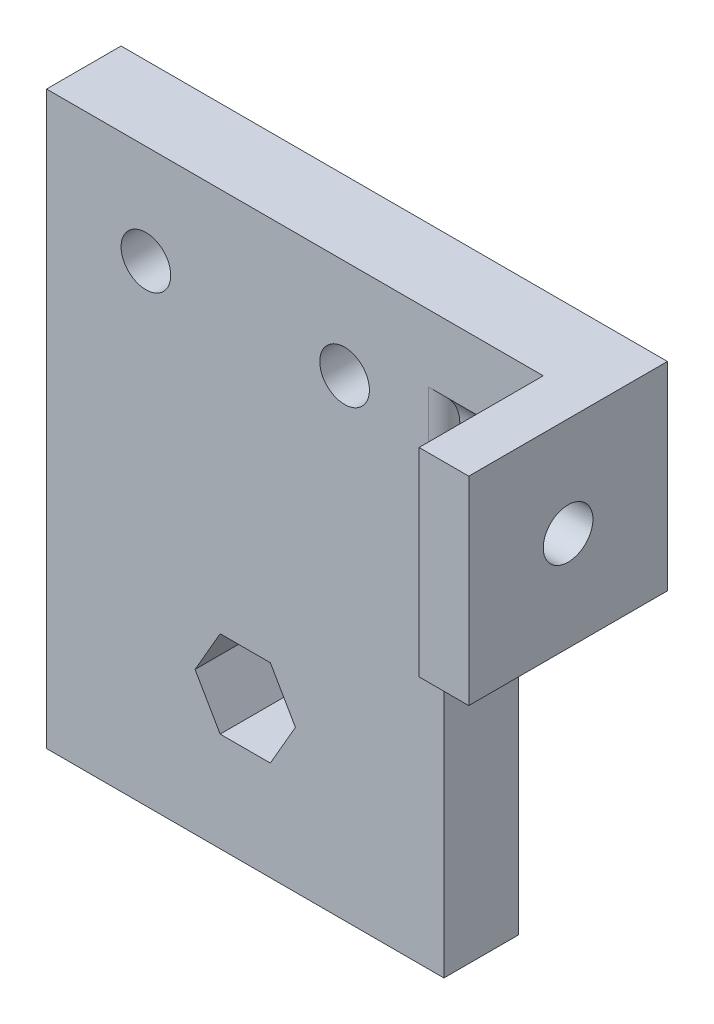
from build123d import *

# Parameters (mm, degrees)
SKETCH2_R      = 3.175
EXTRUDE1_DEPTH = 9.525
EXTRUDE2_START = 12.7
SKETCH3_W      = 25.4
SKETCH3_H      = 25.4
SKETCH3_R      = 3.175
EXTRUDE2_DEPTH = 6.35
SKETCH4_R      = 5.207
EXTRUDE3_DEPTH = 12.7
FILLET4_R      = 2


with BuildPart() as part:
    # Sketch2 → Extrude1 (new body)
    with BuildSketch(Plane.XY):
        Polygon((0, 0), (50.8, 0), (50.8, 47.625), (63.5, 47.625), (63.5, 73.025), (50.8, 73.025), (0, 73.025), align=None)
        with Locations((12.7, 60.325)):
            Circle(SKETCH2_R, mode=Mode.SUBTRACT)
        with Locations((38.1, 60.325)):
            Circle(SKETCH2_R, mode=Mode.SUBTRACT)
        Polygon((31.815804866, 18.25625), (28.607902433, 23.8125), (22.192097567, 23.8125), (18.984195134, 18.25625), (22.192097567, 12.7), (28.607902433, 12.7), align=None, mode=Mode.SUBTRACT)
    extrude(amount=EXTRUDE1_DEPTH)

    # Sketch3 → Extrude2 (add)
    with BuildSketch(Plane(origin=(50.8, 0, 0), x_dir=(0, 0, -1), z_dir=(1, 0, 0)).offset(EXTRUDE2_START)):
        with Locations((-12.7, 60.325)):
            Rectangle(SKETCH3_W, SKETCH3_H)
        with Locations((-12.7, 60.325)):
            Circle(SKETCH3_R, mode=Mode.SUBTRACT)
    extrude(amount=EXTRUDE2_DEPTH)

    # Sketch4 → Extrude3 (cut)
    with BuildSketch(Plane.ZY.offset(-63.5)):
        with Locations((12.7, 60.325)):
            Circle(SKETCH4_R)
    extrude(amount=EXTRUDE3_DEPTH, mode=Mode.SUBTRACT)

    # Fillet4
    fillet4_edges = [part.edges().sort_by_distance(p)[0] for p in [
        (50.8, 60.325, 9.525),
    ]]
    fillet(fillet4_edges, radius=FILLET4_R)


solid = part.part
